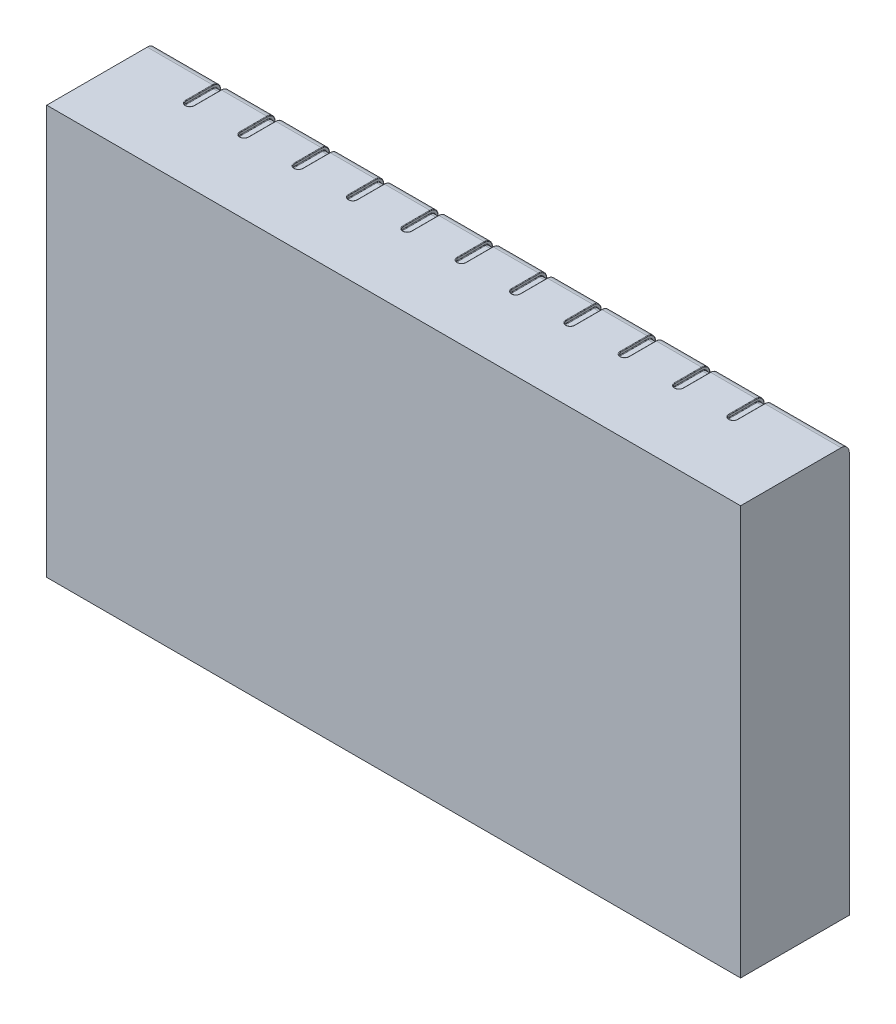
from build123d import *

# Parameters (mm, degrees)
ESQUISSE1_W                      = 255.355755198
ESQUISSE1_H                      = 150.509921672
BOSS_EXTRU_1_DEPTH               = 40
CONG_6_R                         = 3
ESQUISSE3_W                      = 3
ESQUISSE3_H                      = 6
ESQUISSE4_R                      = 1.5
ENL_V_MAT_EXTRU_1_DEPTH          = 1.109525
ESQUISSE5_R                      = 1.5
ENL_V_MAT_EXTRU_2_DEPTH          = 1.109525
CONG_7_R                         = 0.2
R_P_TITION_LIN_AIRE2_COUNT       = 11
R_P_TITION_LIN_AIRE2_PITCH       = 20
CONG_7_OF_R_P_TITION_LIN_AIRE2_R = 0.2


with BuildPart() as part:
    # Esquisse1 → Boss.-Extru.1 (new body)
    with BuildSketch(Plane.XY):
        Rectangle(ESQUISSE1_W, ESQUISSE1_H)
    extrude(amount=BOSS_EXTRU_1_DEPTH)

    # Congé6
    cong_6_edges = [part.edges().sort_by_distance(p)[0] for p in [
        (0, 75.254960836, 0),
    ]]
    fillet(cong_6_edges, radius=CONG_6_R)

    # Enlèvement de matière-Balayage1: sweep along a path in Esquisse2
    with BuildLine(Plane(origin=(97.677877599, 0, 0), x_dir=(0, 0, -1), z_dir=(1, 0, 0))) as enl_vement_de_mati_re_balayage1_path:
        Line((2, 62.254960836), (2, 72.254960836))
        ThreePointArc((2, 72.254960836), (0.535533906, 75.790494741), (-3, 77.254960836))
        Line((-3, 77.254960836), (-13, 77.254960836))
    # Esquisse3 → Enlèvement de matière-Balayage1 (sweep, cut)
    with BuildSketch(Plane(origin=(97.677877599, 77.254960836, 13), x_dir=(-1, 0, 0), z_dir=(0, 0, -1))):
        with Locations((-0.306210447, -0.109525389)):
            Rectangle(ESQUISSE3_W, ESQUISSE3_H)
    enl_vement_de_mati_re_balayage1 = sweep(path=enl_vement_de_mati_re_balayage1_path.line, mode=Mode.SUBTRACT)

    # Esquisse4 → Enlèv. mat.-Extru.1 (cut)
    with BuildSketch(Plane(origin=(0, 75.254960836, 0), x_dir=(1, 0, 0), z_dir=(0, 1, 0))):
        with Locations((97.984088046, -13)):
            Circle(ESQUISSE4_R)
    enl_v_mat_extru_1 = extrude(amount=-ENL_V_MAT_EXTRU_1_DEPTH, mode=Mode.SUBTRACT)

    # Esquisse5 → Enlèv. mat.-Extru.2 (cut)
    with BuildSketch(Plane(origin=(0, 0, 0), x_dir=(-1, 0, 0), z_dir=(0, 0, -1))):
        with Locations((-97.984088046, 62.254960836)):
            Circle(ESQUISSE5_R)
    enl_v_mat_extru_2 = extrude(amount=-ENL_V_MAT_EXTRU_2_DEPTH, mode=Mode.SUBTRACT)

    # Congé7
    cong_7_edges = [part.edges().sort_by_distance(p)[0] for p in [
        (99.484088046, 74.376281179, 0.878679656),
        (96.484088046, 74.376281179, 0.878679656),
        (96.484088046, 74.145435447, 8),
        (99.484088046, 73.591728253, 1.663232583),
        (99.484088046, 67.254960836, 1.109525389),
        (96.484088046, 67.254960836, 1.109525389),
        (96.484088046, 73.591728253, 1.663232583),
        (96.484088046, 75.254960836, 8),
        (96.484088046, 67.254960836, 0),
        (99.484088046, 75.254960836, 8),
        (99.484088046, 67.254960836, 0),
        (99.484088046, 74.145435447, 8),
        (97.984088046, 75.254960836, 14.5),
        (97.984088046, 74.145435836, 14.5),
        (97.984088046, 60.754960836, 0),
        (97.984088046, 60.754960836, 1.109525),
    ]]
    fillet(cong_7_edges, radius=CONG_7_R)

    # Répétition linéaire2: Enlèvement de matière-Balayage1, Enlèv. mat.-Extru.1, Enlèv. mat.-Extru.2 ×11
    with Locations(*[(-i * R_P_TITION_LIN_AIRE2_PITCH, 0, 0) for i in range(1, R_P_TITION_LIN_AIRE2_COUNT)]):
        add(enl_vement_de_mati_re_balayage1, mode=Mode.SUBTRACT)
        add(enl_v_mat_extru_1, mode=Mode.SUBTRACT)
        add(enl_v_mat_extru_2, mode=Mode.SUBTRACT)

    # Congé7 of Répétition linéaire2
    cong_7_of_r_p_tition_lin_aire2_edges = [part.edges().sort_by_distance(p)[0] for p in [
        (79.484088046, 74.376281179, 0.878679656),
        (76.484088046, 74.376281179, 0.878679656),
        (76.484088046, 74.145435447, 8),
        (79.484088046, 73.591728253, 1.663232583),
        (79.484088046, 67.254960836, 1.109525389),
        (76.484088046, 67.254960836, 1.109525389),
        (76.484088046, 73.591728253, 1.663232583),
        (76.484088046, 75.254960836, 8),
        (76.484088046, 67.254960836, 0),
        (79.484088046, 75.254960836, 8),
        (79.484088046, 67.254960836, 0),
        (79.484088046, 74.145435447, 8),
        (77.984088046, 75.254960836, 14.5),
        (77.984088046, 74.145435836, 14.5),
        (77.984088046, 60.754960836, 0),
        (77.984088046, 60.754960836, 1.109525),
        (59.484088046, 74.376281179, 0.878679656),
        (56.484088046, 74.376281179, 0.878679656),
        (56.484088046, 74.145435447, 8),
        (59.484088046, 73.591728253, 1.663232583),
        (59.484088046, 67.254960836, 1.109525389),
        (56.484088046, 67.254960836, 1.109525389),
        (56.484088046, 73.591728253, 1.663232583),
        (56.484088046, 75.254960836, 8),
        (56.484088046, 67.254960836, 0),
        (59.484088046, 75.254960836, 8),
        (59.484088046, 67.254960836, 0),
        (59.484088046, 74.145435447, 8),
        (57.984088046, 75.254960836, 14.5),
        (57.984088046, 74.145435836, 14.5),
        (57.984088046, 60.754960836, 0),
        (57.984088046, 60.754960836, 1.109525),
        (39.484088046, 74.376281179, 0.878679656),
        (36.484088046, 74.376281179, 0.878679656),
        (36.484088046, 74.145435447, 8),
        (39.484088046, 73.591728253, 1.663232583),
        (39.484088046, 67.254960836, 1.109525389),
        (36.484088046, 67.254960836, 1.109525389),
        (36.484088046, 73.591728253, 1.663232583),
        (36.484088046, 75.254960836, 8),
        (36.484088046, 67.254960836, 0),
        (39.484088046, 75.254960836, 8),
        (39.484088046, 67.254960836, 0),
        (39.484088046, 74.145435447, 8),
        (37.984088046, 75.254960836, 14.5),
        (37.984088046, 74.145435836, 14.5),
        (37.984088046, 60.754960836, 0),
        (37.984088046, 60.754960836, 1.109525),
        (19.484088046, 74.376281179, 0.878679656),
        (16.484088046, 74.376281179, 0.878679656),
        (16.484088046, 74.145435447, 8),
        (19.484088046, 73.591728253, 1.663232583),
        (19.484088046, 67.254960836, 1.109525389),
        (16.484088046, 67.254960836, 1.109525389),
        (16.484088046, 73.591728253, 1.663232583),
        (16.484088046, 75.254960836, 8),
        (16.484088046, 67.254960836, 0),
        (19.484088046, 75.254960836, 8),
        (19.484088046, 67.254960836, 0),
        (19.484088046, 74.145435447, 8),
        (17.984088046, 75.254960836, 14.5),
        (17.984088046, 74.145435836, 14.5),
        (17.984088046, 60.754960836, 0),
        (17.984088046, 60.754960836, 1.109525),
        (-0.515911954, 74.376281179, 0.878679656),
        (-3.515911954, 74.376281179, 0.878679656),
        (-3.515911954, 74.145435447, 8),
        (-0.515911954, 73.591728253, 1.663232583),
        (-0.515911954, 67.254960836, 1.109525389),
        (-3.515911954, 67.254960836, 1.109525389),
        (-3.515911954, 73.591728253, 1.663232583),
        (-3.515911954, 75.254960836, 8),
        (-3.515911954, 67.254960836, 0),
        (-0.515911954, 75.254960836, 8),
        (-0.515911954, 67.254960836, 0),
        (-0.515911954, 74.145435447, 8),
        (-2.015911954, 75.254960836, 14.5),
        (-2.015911954, 74.145435836, 14.5),
        (-2.015911954, 60.754960836, 0),
        (-2.015911954, 60.754960836, 1.109525),
        (-20.515911954, 74.376281179, 0.878679656),
        (-23.515911954, 74.376281179, 0.878679656),
        (-23.515911954, 74.145435447, 8),
        (-20.515911954, 73.591728253, 1.663232583),
        (-20.515911954, 67.254960836, 1.109525389),
        (-23.515911954, 67.254960836, 1.109525389),
        (-23.515911954, 73.591728253, 1.663232583),
        (-23.515911954, 75.254960836, 8),
        (-23.515911954, 67.254960836, 0),
        (-20.515911954, 75.254960836, 8),
        (-20.515911954, 67.254960836, 0),
        (-20.515911954, 74.145435447, 8),
        (-22.015911954, 75.254960836, 14.5),
        (-22.015911954, 74.145435836, 14.5),
        (-22.015911954, 60.754960836, 0),
        (-22.015911954, 60.754960836, 1.109525),
        (-40.515911954, 74.376281179, 0.878679656),
        (-43.515911954, 74.376281179, 0.878679656),
        (-43.515911954, 74.145435447, 8),
        (-40.515911954, 73.591728253, 1.663232583),
        (-40.515911954, 67.254960836, 1.109525389),
        (-43.515911954, 67.254960836, 1.109525389),
        (-43.515911954, 73.591728253, 1.663232583),
        (-43.515911954, 75.254960836, 8),
        (-43.515911954, 67.254960836, 0),
        (-40.515911954, 75.254960836, 8),
        (-40.515911954, 67.254960836, 0),
        (-40.515911954, 74.145435447, 8),
        (-42.015911954, 75.254960836, 14.5),
        (-42.015911954, 74.145435836, 14.5),
        (-42.015911954, 60.754960836, 0),
        (-42.015911954, 60.754960836, 1.109525),
        (-60.515911954, 74.376281179, 0.878679656),
        (-63.515911954, 74.376281179, 0.878679656),
        (-63.515911954, 74.145435447, 8),
        (-60.515911954, 73.591728253, 1.663232583),
        (-60.515911954, 67.254960836, 1.109525389),
        (-63.515911954, 67.254960836, 1.109525389),
        (-63.515911954, 73.591728253, 1.663232583),
        (-63.515911954, 75.254960836, 8),
        (-63.515911954, 67.254960836, 0),
        (-60.515911954, 75.254960836, 8),
        (-60.515911954, 67.254960836, 0),
        (-60.515911954, 74.145435447, 8),
        (-62.015911954, 75.254960836, 14.5),
        (-62.015911954, 74.145435836, 14.5),
        (-62.015911954, 60.754960836, 0),
        (-62.015911954, 60.754960836, 1.109525),
        (-80.515911954, 74.376281179, 0.878679656),
        (-83.515911954, 74.376281179, 0.878679656),
        (-83.515911954, 74.145435447, 8),
        (-80.515911954, 73.591728253, 1.663232583),
        (-80.515911954, 67.254960836, 1.109525389),
        (-83.515911954, 67.254960836, 1.109525389),
        (-83.515911954, 73.591728253, 1.663232583),
        (-83.515911954, 75.254960836, 8),
        (-83.515911954, 67.254960836, 0),
        (-80.515911954, 75.254960836, 8),
        (-80.515911954, 67.254960836, 0),
        (-80.515911954, 74.145435447, 8),
        (-82.015911954, 75.254960836, 14.5),
        (-82.015911954, 74.145435836, 14.5),
        (-82.015911954, 60.754960836, 0),
        (-82.015911954, 60.754960836, 1.109525),
        (-100.515911954, 74.376281179, 0.878679656),
        (-103.515911954, 74.376281179, 0.878679656),
        (-103.515911954, 74.145435447, 8),
        (-100.515911954, 73.591728253, 1.663232583),
        (-100.515911954, 67.254960836, 1.109525389),
        (-103.515911954, 67.254960836, 1.109525389),
        (-103.515911954, 73.591728253, 1.663232583),
        (-103.515911954, 75.254960836, 8),
        (-103.515911954, 67.254960836, 0),
        (-100.515911954, 75.254960836, 8),
        (-100.515911954, 67.254960836, 0),
        (-100.515911954, 74.145435447, 8),
        (-102.015911954, 75.254960836, 14.5),
        (-102.015911954, 74.145435836, 14.5),
        (-102.015911954, 60.754960836, 0),
        (-102.015911954, 60.754960836, 1.109525),
    ]]
    fillet(cong_7_of_r_p_tition_lin_aire2_edges, radius=CONG_7_OF_R_P_TITION_LIN_AIRE2_R)


solid = part.part
